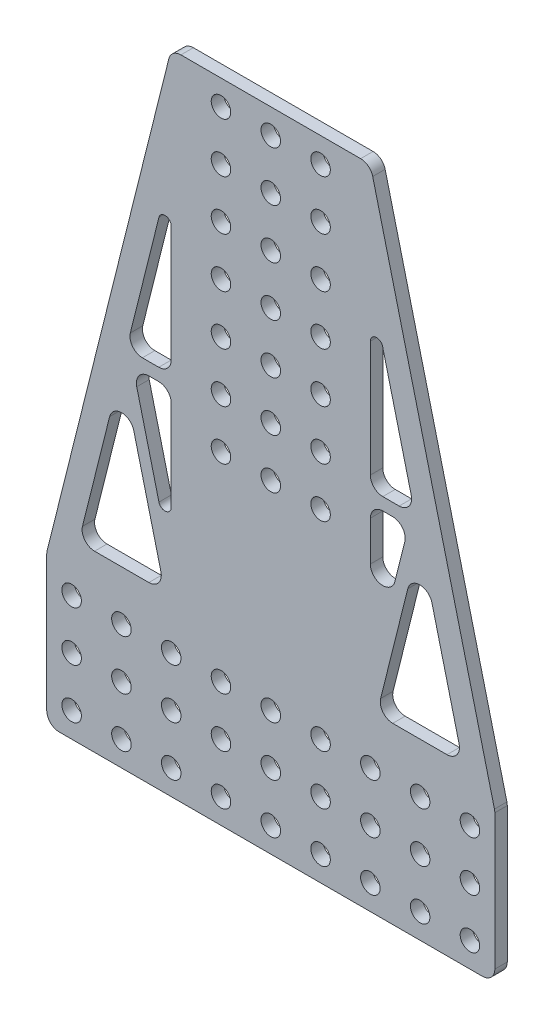
from build123d import *
from OCP.BRepFilletAPI import BRepFilletAPI_MakeFillet

# Parameters (mm, degrees)
SKETCH1_R           = 2.4892
BOSS_EXTRUDE1_DEPTH = 3.175
CUT_EXTRUDE1_DEPTH  = 230.414348124
FILLET1_R1          = 3.175
FILLET1_R2          = 1.5875
FILLET2_R           = 3.175


with BuildPart() as part:
    # Sketch1 → Boss-Extrude1 (new body)
    with BuildSketch(Plane.XY):
        Polygon((69.85, 171.45), (38.1, 44.45), (38.1, 6.35), (152.4, 6.35), (152.4, 44.45), (120.65, 171.45), align=None)
        with Locations((107.95, 152.4)):
            Circle(SKETCH1_R, mode=Mode.SUBTRACT)
        with Locations((107.95, 139.7)):
            Circle(SKETCH1_R, mode=Mode.SUBTRACT)
        with Locations((107.95, 165.1)):
            Circle(SKETCH1_R, mode=Mode.SUBTRACT)
        with Locations((82.55, 88.9)):
            Circle(SKETCH1_R, mode=Mode.SUBTRACT)
        with Locations((95.25, 88.9)):
            Circle(SKETCH1_R, mode=Mode.SUBTRACT)
        with Locations((82.55, 101.6)):
            Circle(SKETCH1_R, mode=Mode.SUBTRACT)
        with Locations((95.25, 101.6)):
            Circle(SKETCH1_R, mode=Mode.SUBTRACT)
        with Locations((82.55, 114.3)):
            Circle(SKETCH1_R, mode=Mode.SUBTRACT)
        with Locations((95.25, 114.3)):
            Circle(SKETCH1_R, mode=Mode.SUBTRACT)
        with Locations((107.95, 88.9)):
            Circle(SKETCH1_R, mode=Mode.SUBTRACT)
        with Locations((107.95, 101.6)):
            Circle(SKETCH1_R, mode=Mode.SUBTRACT)
        with Locations((107.95, 114.3)):
            Circle(SKETCH1_R, mode=Mode.SUBTRACT)
        with Locations((82.55, 127)):
            Circle(SKETCH1_R, mode=Mode.SUBTRACT)
        with Locations((95.25, 127)):
            Circle(SKETCH1_R, mode=Mode.SUBTRACT)
        with Locations((82.55, 139.7)):
            Circle(SKETCH1_R, mode=Mode.SUBTRACT)
        with Locations((95.25, 139.7)):
            Circle(SKETCH1_R, mode=Mode.SUBTRACT)
        with Locations((82.55, 152.4)):
            Circle(SKETCH1_R, mode=Mode.SUBTRACT)
        with Locations((95.25, 152.4)):
            Circle(SKETCH1_R, mode=Mode.SUBTRACT)
        with Locations((82.55, 165.1)):
            Circle(SKETCH1_R, mode=Mode.SUBTRACT)
        with Locations((95.25, 165.1)):
            Circle(SKETCH1_R, mode=Mode.SUBTRACT)
        with Locations((107.95, 127)):
            Circle(SKETCH1_R, mode=Mode.SUBTRACT)
        with Locations((146.05, 38.1)):
            Circle(SKETCH1_R, mode=Mode.SUBTRACT)
        with Locations((44.45, 12.7)):
            Circle(SKETCH1_R, mode=Mode.SUBTRACT)
        with Locations((44.45, 25.4)):
            Circle(SKETCH1_R, mode=Mode.SUBTRACT)
        with Locations((44.45, 38.1)):
            Circle(SKETCH1_R, mode=Mode.SUBTRACT)
        with Locations((57.15, 12.7)):
            Circle(SKETCH1_R, mode=Mode.SUBTRACT)
        with Locations((69.85, 12.7)):
            Circle(SKETCH1_R, mode=Mode.SUBTRACT)
        with Locations((57.15, 25.4)):
            Circle(SKETCH1_R, mode=Mode.SUBTRACT)
        with Locations((69.85, 25.4)):
            Circle(SKETCH1_R, mode=Mode.SUBTRACT)
        with Locations((82.55, 12.7)):
            Circle(SKETCH1_R, mode=Mode.SUBTRACT)
        with Locations((95.25, 12.7)):
            Circle(SKETCH1_R, mode=Mode.SUBTRACT)
        with Locations((82.55, 25.4)):
            Circle(SKETCH1_R, mode=Mode.SUBTRACT)
        with Locations((95.25, 25.4)):
            Circle(SKETCH1_R, mode=Mode.SUBTRACT)
        with Locations((57.15, 38.1)):
            Circle(SKETCH1_R, mode=Mode.SUBTRACT)
        with Locations((69.85, 38.1)):
            Circle(SKETCH1_R, mode=Mode.SUBTRACT)
        with Locations((82.55, 38.1)):
            Circle(SKETCH1_R, mode=Mode.SUBTRACT)
        with Locations((95.25, 38.1)):
            Circle(SKETCH1_R, mode=Mode.SUBTRACT)
        with Locations((107.95, 12.7)):
            Circle(SKETCH1_R, mode=Mode.SUBTRACT)
        with Locations((120.65, 12.7)):
            Circle(SKETCH1_R, mode=Mode.SUBTRACT)
        with Locations((107.95, 25.4)):
            Circle(SKETCH1_R, mode=Mode.SUBTRACT)
        with Locations((120.65, 25.4)):
            Circle(SKETCH1_R, mode=Mode.SUBTRACT)
        with Locations((133.35, 12.7)):
            Circle(SKETCH1_R, mode=Mode.SUBTRACT)
        with Locations((146.05, 12.7)):
            Circle(SKETCH1_R, mode=Mode.SUBTRACT)
        with Locations((133.35, 25.4)):
            Circle(SKETCH1_R, mode=Mode.SUBTRACT)
        with Locations((146.05, 25.4)):
            Circle(SKETCH1_R, mode=Mode.SUBTRACT)
        with Locations((107.95, 38.1)):
            Circle(SKETCH1_R, mode=Mode.SUBTRACT)
        with Locations((120.65, 38.1)):
            Circle(SKETCH1_R, mode=Mode.SUBTRACT)
        with Locations((133.35, 38.1)):
            Circle(SKETCH1_R, mode=Mode.SUBTRACT)
    extrude(amount=BOSS_EXTRUDE1_DEPTH)

    # Sketch2 → Cut-Extrude1 (cut, through all)
    with BuildSketch(Plane.XY.offset(3.175)):
        Polygon((122.286357545, 50.8), (144.267069819, 50.8), (133.276713682, 94.761424548), align=None)
        Polygon((120.65, 99.621639639), (132.06165991, 99.621639639), (120.65, 145.268279277), align=None)
        Polygon((120.65, 96.446639639), (120.65, 57.345430181), (130.425302364, 96.446639639), align=None)
        Polygon((69.85, 96.446639639), (60.074697636, 96.446639639), (69.85, 57.345430181), align=None)
        Polygon((58.43834009, 99.621639639), (69.85, 99.621639639), (69.85, 145.268279277), align=None)
        Polygon((46.232930181, 50.8), (68.213642455, 50.8), (57.223286318, 94.761424548), align=None)
    extrude(amount=-CUT_EXTRUDE1_DEPTH, mode=Mode.SUBTRACT)

    # Fillet1: one fillet with a radius per group of edges: ONE call of the kernel's fillet builder (fillet() takes one radius for all edges)
    fillet1_edges_1 = [part.edges().sort_by_distance(p)[0] for p in [
        (46.232930181, 50.8, 1.5875),
        (57.223286318, 94.761424548, 1.5875),
        (68.213642455, 50.8, 1.5875),
        (60.074697636, 96.446639639, 1.5875),
        (69.85, 96.446639639, 1.5875),
        (69.85, 99.621639639, 1.5875),
        (58.43834009, 99.621639639, 1.5875),
        (120.65, 57.345430181, 1.5875),
        (132.06165991, 99.621639639, 1.5875),
        (120.65, 99.621639639, 1.5875),
        (120.65, 96.446639639, 1.5875),
        (130.425302364, 96.446639639, 1.5875),
        (133.276713682, 94.761424548, 1.5875),
        (122.286357545, 50.8, 1.5875),
        (144.267069819, 50.8, 1.5875),
    ]]
    fillet1_edges_2 = [part.edges().sort_by_distance(p)[0] for p in [
        (69.85, 145.268279277, 1.5875),
        (69.85, 57.345430181, 1.5875),
        (120.65, 145.268279277, 1.5875),
    ]]
    fillet1 = BRepFilletAPI_MakeFillet(part.part.solid().wrapped)
    for e in fillet1_edges_1:
        fillet1.Add(FILLET1_R1, e.wrapped)
    for e in fillet1_edges_2:
        fillet1.Add(FILLET1_R2, e.wrapped)
    add(Compound.cast(fillet1.Shape()), mode=Mode.REPLACE)

    # Fillet2
    fillet2_edges = [part.edges().sort_by_distance(p)[0] for p in [
        (120.65, 171.45, 1.5875),
        (152.4, 44.45, 1.5875),
        (152.4, 6.35, 1.5875),
        (38.1, 6.35, 1.5875),
        (38.1, 44.45, 1.5875),
        (69.85, 171.45, 1.5875),
    ]]
    fillet(fillet2_edges, radius=FILLET2_R)


solid = part.part
